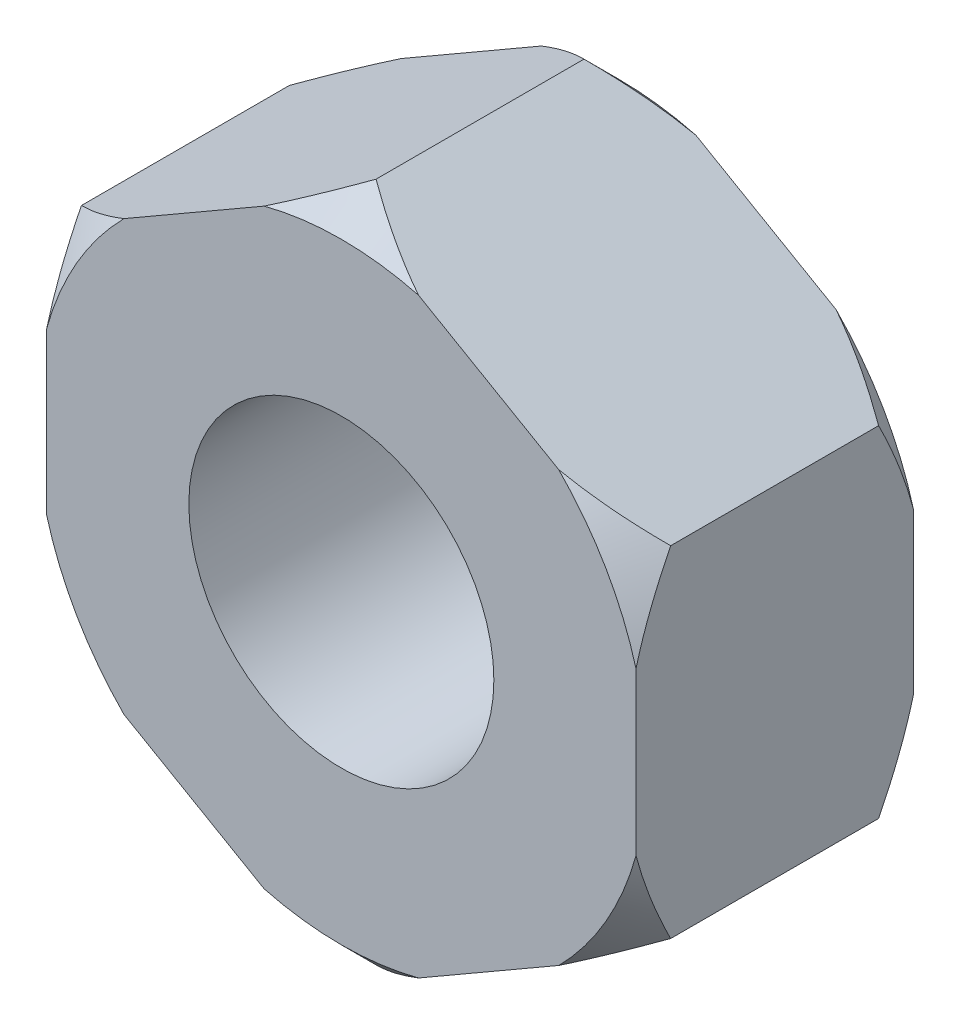
from build123d import *

# Parameters (mm, degrees)
BOSS_EXTRUDE1_DEPTH         = 8
M10X1_25_TAPPED_HOLE1_D     = 8.8
M10X1_25_TAPPED_HOLE1_DEPTH = 23.75
M10X1_25_TAPPED_HOLE1_TIP   = 2.643786724


with BuildPart() as part:
    # Sketch1 → Boss-Extrude1 (new body)
    with BuildSketch(Plane.XY):
        Polygon((0, -9.814954576), (8.5, -4.907477288), (8.5, 4.907477288), (0, 9.814954576), (-8.5, 4.907477288), (-8.5, -4.907477288), align=None)
    extrude(amount=BOSS_EXTRUDE1_DEPTH)

    # Sketch3 → Cut-Revolve8 (revolve, cut)
    with BuildSketch(Plane(origin=(0, 0, 0), x_dir=(0, 0, -1), z_dir=(1, 0, 0))):
        Polygon((-1, 9.814954576), (0, 8.814954576), (0, 9.814954576), align=None)
        Polygon((-8, 8.814954576), (-8, 9.814954576), (-7, 9.814954576), align=None)
    revolve(axis=Axis((0, 0, 0), (0, 0, -1)), mode=Mode.SUBTRACT)

    # M10x1.25 Tapped Hole1
    with Locations(Plane.XY.offset(8)):
        with Locations((0, 0)):
            Hole(M10X1_25_TAPPED_HOLE1_D / 2, depth=M10X1_25_TAPPED_HOLE1_DEPTH)
            with Locations((0, 0, -(M10X1_25_TAPPED_HOLE1_DEPTH + M10X1_25_TAPPED_HOLE1_TIP / 2))):  # 118° drill point
                Cone(0, M10X1_25_TAPPED_HOLE1_D / 2, M10X1_25_TAPPED_HOLE1_TIP, mode=Mode.SUBTRACT)


solid = part.part
